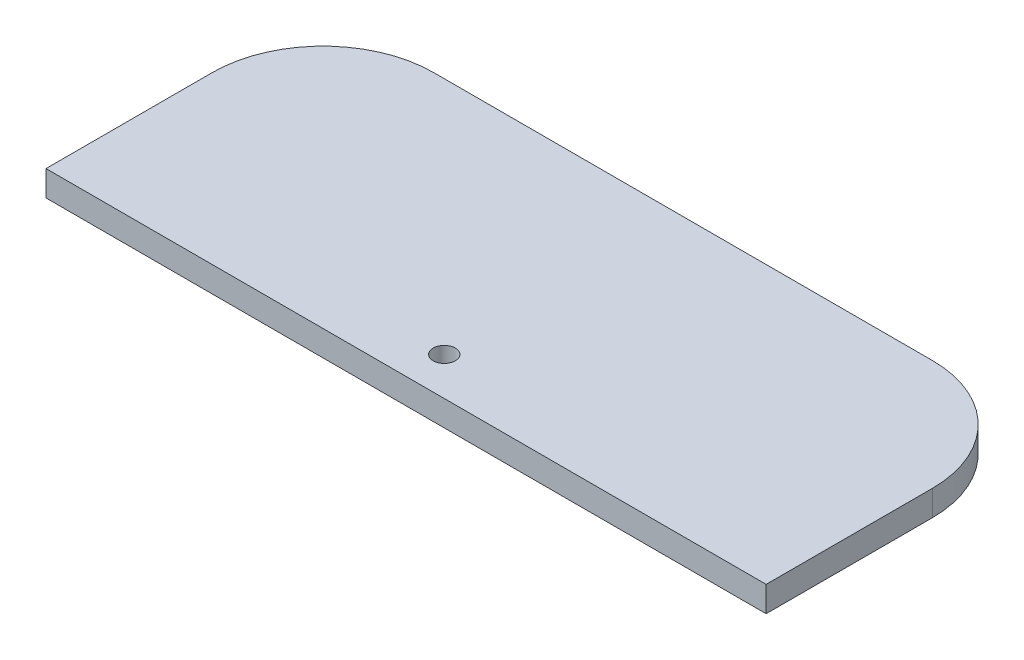
from build123d import *

# Parameters (mm, degrees)
SKETCH2_W           = 65
SKETCH2_H           = 25
SKETCH2_R           = 1
BOSS_EXTRUDE1_DEPTH = 2.3
FILLET9_R           = 10


with BuildPart() as part:
    # Sketch2 → Boss-Extrude1 (new body)
    with BuildSketch(Plane(origin=(0, 0, 0), x_dir=(1, 0, 0), z_dir=(0, 1, 0))):
        Rectangle(SKETCH2_W, SKETCH2_H)
        with Locations((0, -9.054487493)):
            Circle(SKETCH2_R, mode=Mode.SUBTRACT)
    extrude(amount=BOSS_EXTRUDE1_DEPTH)

    # Fillet9
    fillet9_edges = [part.edges().sort_by_distance(p)[0] for p in [
        (-32.5, 1.15, -12.5),
        (32.5, 1.15, -12.5),
    ]]
    fillet(fillet9_edges, radius=FILLET9_R)


solid = part.part
